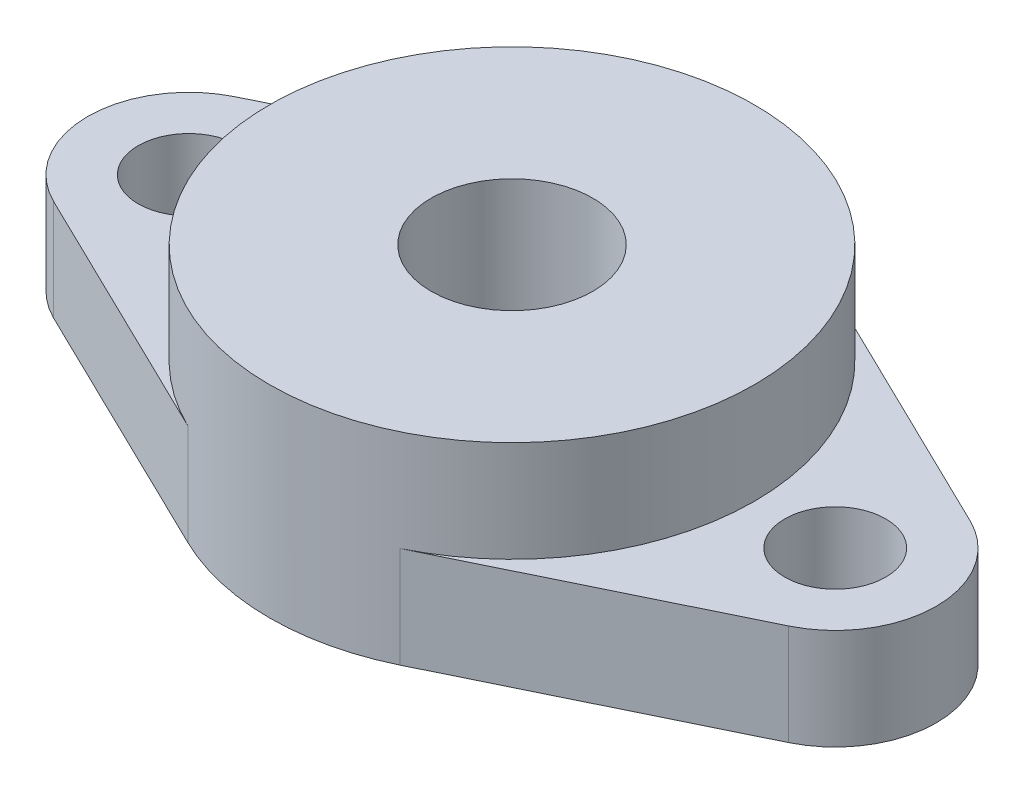
from build123d import *

# Parameters (mm, degrees)
EXTRUDE_1_DEPTH     = 5
SKETCH_3_R          = 12
EXTRUDE_2_DEPTH     = 5
SKETCH_4_R          = 4
CUT_EXTRUDE_1_DEPTH = 11
SKETCH_6_R          = 2.5
CUT_EXTRUDE_2_DEPTH = 11


with BuildPart() as part:
    # 草图1 → 凸台-拉伸1 (new body)
    with BuildSketch(Plane(origin=(0, 0, 0), x_dir=(1, 0, 0), z_dir=(0, 1, 0))):
        with BuildLine():
            Line((-5.25, 10.790620927), (-18.1875, 4.496092053))
            ThreePointArc((-18.1875, 4.496092053), (-21, 0), (-18.1875, -4.496092053))
            Line((-18.1875, -4.496092053), (-5.25, -10.790620927))
            ThreePointArc((-5.25, -10.790620927), (0, -12), (5.25, -10.790620927))
            Line((5.25, -10.790620927), (18.1875, -4.496092053))
            ThreePointArc((18.1875, -4.496092053), (21, 0), (18.1875, 4.496092053))
            Line((18.1875, 4.496092053), (5.25, 10.790620927))
            ThreePointArc((5.25, 10.790620927), (0, 12), (-5.25, 10.790620927))
        make_face()
    extrude(amount=EXTRUDE_1_DEPTH)

    # 草图3 → 凸台-拉伸2 (add)
    with BuildSketch(Plane(origin=(0, 5, 0), x_dir=(1, 0, 0), z_dir=(0, 1, 0))):
        Circle(SKETCH_3_R)
    extrude(amount=EXTRUDE_2_DEPTH)

    # 草图4 → 切除-拉伸1 (cut, through all)
    with BuildSketch(Plane(origin=(0, 10, 0), x_dir=(1, 0, 0), z_dir=(0, 1, 0))):
        Circle(SKETCH_4_R)
    extrude(amount=-CUT_EXTRUDE_1_DEPTH, mode=Mode.SUBTRACT)

    # 草图6 → 切除-拉伸2 (cut, through all)
    with BuildSketch(Plane.XZ):
        with Locations((-16, 0)):
            Circle(SKETCH_6_R)
        with Locations((16, 0)):
            Circle(SKETCH_6_R)
    extrude(amount=-CUT_EXTRUDE_2_DEPTH, mode=Mode.SUBTRACT)


solid = part.part
